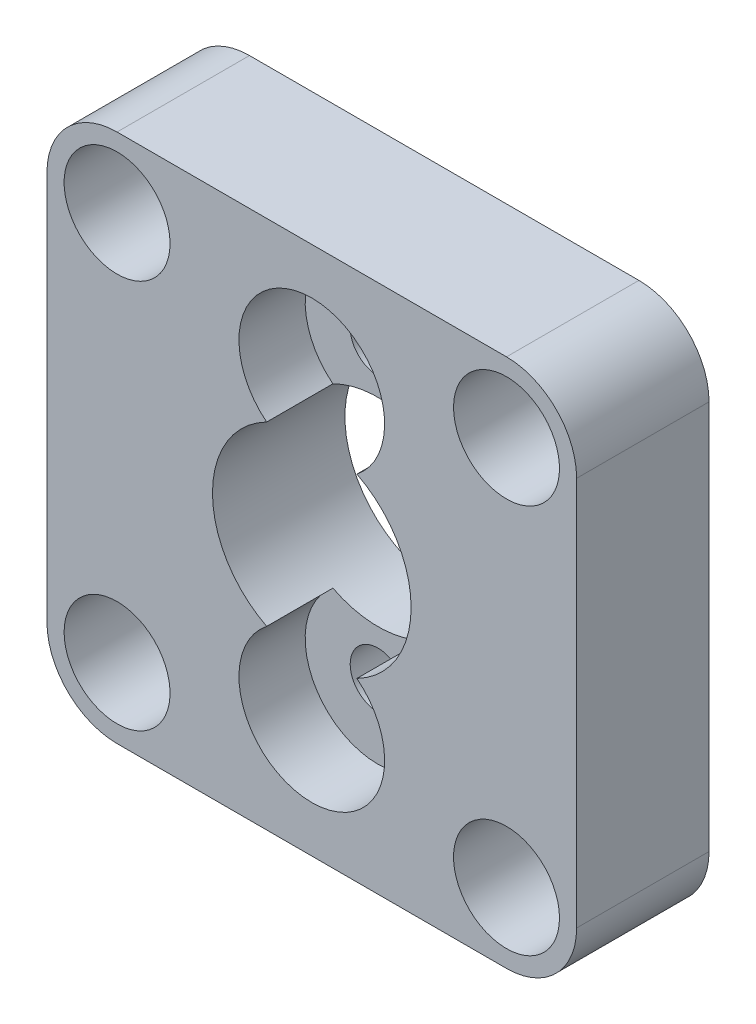
from build123d import *

# Parameters (mm, degrees)
SKIZZE3_W                       = 20
SKIZZE3_H                       = 20
SKIZZE3_R                       = 7.5
AUFSATZ_LINEAR_AUSTRAGEN2_DEPTH = 5
SKIZZE4_R                       = 1.05
SCHNITT_LINEAR_AUSTRAGEN1_DEPTH = 6
SKIZZE5_R                       = 2.75
SCHNITT_LINEAR_AUSTRAGEN2_DEPTH = 2.5
SCHNITT_LINEAR_AUSTRAGEN3_DEPTH = 6
SKIZZE7_R                       = 1.15
SCHNITT_LINEAR_AUSTRAGEN4_DEPTH = 6
SKIZZE8_R                       = 2
SCHNITT_LINEAR_AUSTRAGEN5_DEPTH = 3
SKIZZE10_R                      = 3.75
SCHNITT_LINEAR_AUSTRAGEN6_DEPTH = 6


with BuildPart() as part:
    # Skizze2 → Rotation1 (revolve)
    with BuildSketch(Plane(origin=(0, 0, 0), x_dir=(0, 0, -1), z_dir=(1, 0, 0))):
        Polygon((0, 3.75), (-1, 3.75), (-1, 3.25), (-2.6, 3.25), (-2.6, 2), (-5, 2), (-5, 7.5), (0, 7.5), align=None)
    revolve(axis=Axis((0, 0, 12.6), (0, 0, -1)))

    # Skizze3 → Aufsatz-Linear austragen2 (add, through all)
    with BuildSketch(Plane.XY.offset(5)):
        Rectangle(SKIZZE3_W, SKIZZE3_H)
        Circle(SKIZZE3_R, mode=Mode.SUBTRACT)
    extrude(amount=-AUFSATZ_LINEAR_AUSTRAGEN2_DEPTH)

    # Skizze4 → Schnitt-Linear austragen1 (cut, through all)
    with BuildSketch(Plane.XY.offset(5)):
        with Locations((0, 5.5)):
            Circle(SKIZZE4_R)
        with Locations((0, -5.5)):
            Circle(SKIZZE4_R)
    extrude(amount=-SCHNITT_LINEAR_AUSTRAGEN1_DEPTH, mode=Mode.SUBTRACT)

    # Skizze5 → Schnitt-Linear austragen2 (cut)
    with BuildSketch(Plane.XY.offset(5)):
        with Locations((0, 5.5)):
            Circle(SKIZZE5_R)
        with Locations((0, -5.5)):
            Circle(SKIZZE5_R)
    extrude(amount=-SCHNITT_LINEAR_AUSTRAGEN2_DEPTH, mode=Mode.SUBTRACT)

    # Skizze6 → Schnitt-Linear austragen3 (cut, through all)
    with BuildSketch(Plane.XY.offset(5)):
        with BuildLine():
            Line((-10, 7.352290732), (-10.887824638, 7.352290732))
            Line((-10.887824638, 7.352290732), (-10.887824638, 10.887824638))
            Line((-10.887824638, 10.887824638), (-7.352290732, 10.887824638))
            Line((-7.352290732, 10.887824638), (-7.352290732, 10))
            ThreePointArc((-7.352290732, 10), (-9.22450391, 9.22450391), (-10, 7.352290732))
        make_face()
        with BuildLine():
            Line((7.352290732, 10.887824638), (7.352290732, 10))
            ThreePointArc((7.352290732, 10), (9.22450391, 9.22450391), (10, 7.352290732))
            Line((10, 7.352290732), (10.887824638, 7.352290732))
            Line((10.887824638, 7.352290732), (10.887824638, 10.887824638))
            Line((10.887824638, 10.887824638), (7.352290732, 10.887824638))
        make_face()
        with BuildLine():
            Line((10, -7.352290732), (10.887824638, -7.352290732))
            Line((10.887824638, -7.352290732), (10.887824638, -10.887824638))
            Line((10.887824638, -10.887824638), (7.352290732, -10.887824638))
            Line((7.352290732, -10.887824638), (7.352290732, -10))
            ThreePointArc((7.352290732, -10), (9.22450391, -9.22450391), (10, -7.352290732))
        make_face()
        with BuildLine():
            Line((-7.352290732, -10.887824638), (-7.352290732, -10))
            ThreePointArc((-7.352290732, -10), (-9.22450391, -9.22450391), (-10, -7.352290732))
            Line((-10, -7.352290732), (-10.887824638, -7.352290732))
            Line((-10.887824638, -7.352290732), (-10.887824638, -10.887824638))
            Line((-10.887824638, -10.887824638), (-7.352290732, -10.887824638))
        make_face()
    extrude(amount=-SCHNITT_LINEAR_AUSTRAGEN3_DEPTH, mode=Mode.SUBTRACT)

    # Skizze7 → Schnitt-Linear austragen4 (cut, through all)
    with BuildSketch(Plane.XY.offset(5)):
        with Locations((-7.352290732, 7.352290732)):
            Circle(SKIZZE7_R)
        with Locations((7.352290732, 7.352290732)):
            Circle(SKIZZE7_R)
        with Locations((7.352290732, -7.352290732)):
            Circle(SKIZZE7_R)
        with Locations((-7.352290732, -7.352290732)):
            Circle(SKIZZE7_R)
    extrude(amount=-SCHNITT_LINEAR_AUSTRAGEN4_DEPTH, mode=Mode.SUBTRACT)

    # Skizze8 → Schnitt-Linear austragen5 (cut)
    with BuildSketch(Plane.XY.offset(5)):
        with Locations((-7.352290732, 7.352290732)):
            Circle(SKIZZE8_R)
        with Locations((7.352290732, 7.352290732)):
            Circle(SKIZZE8_R)
        with Locations((7.352290732, -7.352290732)):
            Circle(SKIZZE8_R)
        with Locations((-7.352290732, -7.352290732)):
            Circle(SKIZZE8_R)
    extrude(amount=-SCHNITT_LINEAR_AUSTRAGEN5_DEPTH, mode=Mode.SUBTRACT)

    # Skizze10 → Schnitt-Linear austragen6 (cut, through all)
    with BuildSketch(Plane(origin=(0, 0, 0), x_dir=(-1, 0, 0), z_dir=(0, 0, -1))):
        Circle(SKIZZE10_R)
    extrude(amount=-SCHNITT_LINEAR_AUSTRAGEN6_DEPTH, mode=Mode.SUBTRACT)


solid = part.part
